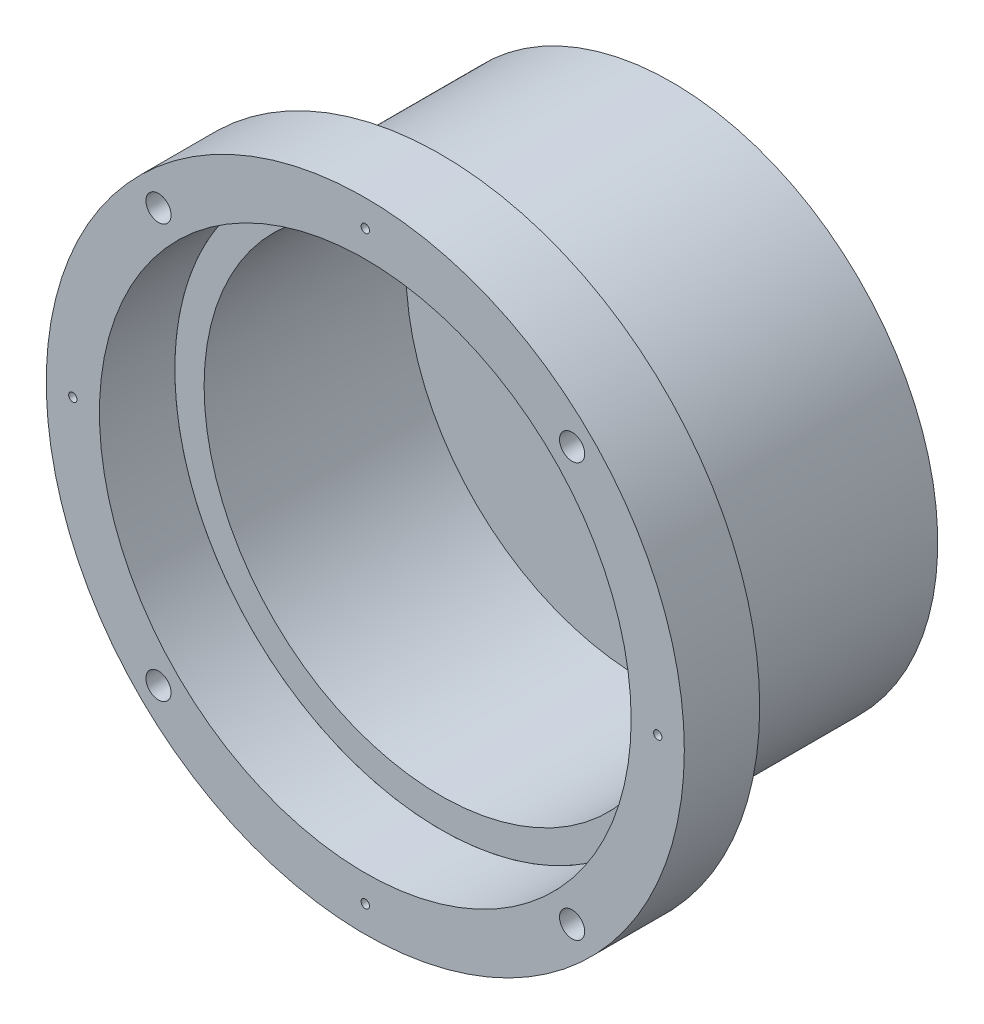
from build123d import *

# Parameters (mm, degrees)
SKETCH1_R           = 76.2
SKETCH1_R_2         = 63.5
BOSS_EXTRUDE1_DEPTH = 28.225
SKETCH3_R           = 3
CUT_EXTRUDE2_DEPTH  = 29.225
SKETCH4_R           = 107.957941083
CUT_EXTRUDE3_DEPTH  = 10.225
SKETCH5_R           = 63.5
SKETCH5_R_2         = 56.5
BOSS_EXTRUDE2_DEPTH = 55.225
SKETCH6_R           = 56.5
BOSS_EXTRUDE3_DEPTH = 7
SKETCH7_R           = 2
CUT_EXTRUDE4_DEPTH  = 10
SKETCH8_R           = 1
CUT_EXTRUDE5_DEPTH  = 19


with BuildPart() as part:
    # Sketch1 → Boss-Extrude1 (new body)
    with BuildSketch(Plane.XY):
        Circle(SKETCH1_R)
        Circle(SKETCH1_R_2, mode=Mode.SUBTRACT)
    extrude(amount=BOSS_EXTRUDE1_DEPTH)

    # Sketch3 → Cut-Extrude2 (cut, through all)
    with BuildSketch(Plane.XY.offset(28.225)):
        with Locations((-49.391408666, 49.391408666)):
            Circle(SKETCH3_R)
        with Locations((49.391408666, 49.391408666)):
            Circle(SKETCH3_R)
        with Locations((49.391408666, -49.391408666)):
            Circle(SKETCH3_R)
        with Locations((-49.391408666, -49.391408666)):
            Circle(SKETCH3_R)
    extrude(amount=-CUT_EXTRUDE2_DEPTH, mode=Mode.SUBTRACT)

    # Sketch4 → Cut-Extrude3 (cut)
    with BuildSketch(Plane.XY.offset(28.225)):
        Circle(SKETCH4_R)
    extrude(amount=-CUT_EXTRUDE3_DEPTH, mode=Mode.SUBTRACT)

    # Sketch7 → Cut-Extrude4 (cut)
    with BuildSketch(Plane(origin=(0, 0, 0), x_dir=(-1, 0, 0), z_dir=(0, 0, -1))):
        with Locations((0, 69.85)):
            Circle(SKETCH7_R)
        with Locations((69.85, 0)):
            Circle(SKETCH7_R)
        with Locations((0, -69.85)):
            Circle(SKETCH7_R)
        with Locations((-69.85, 0)):
            Circle(SKETCH7_R)
    extrude(amount=-CUT_EXTRUDE4_DEPTH, mode=Mode.SUBTRACT)

    # Sketch8 → Cut-Extrude5 (cut, through all)
    with BuildSketch(Plane(origin=(0, 0, 0), x_dir=(-1, 0, 0), z_dir=(0, 0, -1))):
        with Locations((0, 69.85)):
            Circle(SKETCH8_R)
        with Locations((69.85, 0)):
            Circle(SKETCH8_R)
        with Locations((0, -69.85)):
            Circle(SKETCH8_R)
        with Locations((-69.85, 0)):
            Circle(SKETCH8_R)
    extrude(amount=-CUT_EXTRUDE5_DEPTH, mode=Mode.SUBTRACT)


with BuildPart() as body_2:
    # Sketch5 → Boss-Extrude2 (new body)
    with BuildSketch(Plane(origin=(0, 0, 0), x_dir=(-1, 0, 0), z_dir=(0, 0, -1))):
        Circle(SKETCH5_R)
        Circle(SKETCH5_R_2, mode=Mode.SUBTRACT)
    extrude(amount=BOSS_EXTRUDE2_DEPTH)

    # Sketch6 → Boss-Extrude3 (add)
    with BuildSketch(Plane(origin=(0, 0, -55.225), x_dir=(-1, 0, 0), z_dir=(0, 0, -1))):
        Circle(SKETCH6_R)
    extrude(amount=-BOSS_EXTRUDE3_DEPTH)


solid = Compound([part.part, body_2.part])
